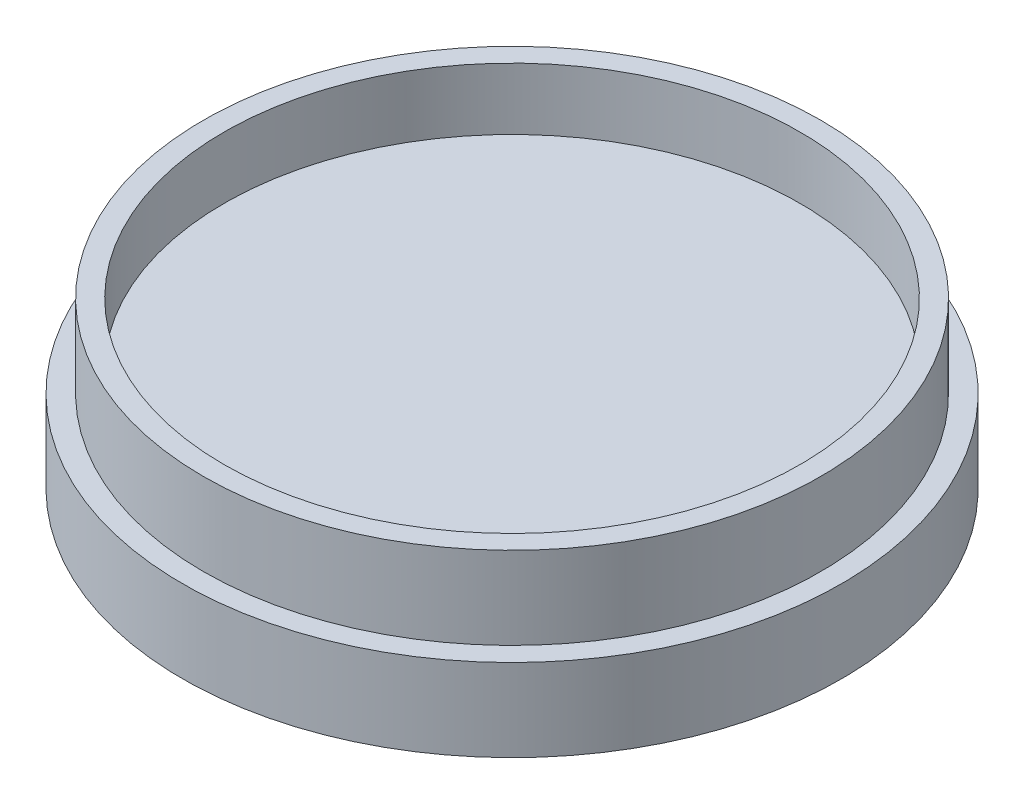
from build123d import *

# Parameters (mm, degrees)
SKETCH1_R           = 95.149999946
BOSS_EXTRUDE1_DEPTH = 25.4
SKETCH2_R           = 88.8
CUT_EXTRUDE1_DEPTH  = 19.05
SKETCH3_R           = 101.6
BOSS_EXTRUDE2_DEPTH = 25.4
SKETCH4_R           = 12.827
CUT_EXTRUDE2_DEPTH  = 19.05


with BuildPart() as part:
    # Sketch1 → Boss-Extrude1 (new body)
    with BuildSketch(Plane(origin=(0, 0, 0), x_dir=(1, 0, 0), z_dir=(0, 1, 0))):
        Circle(SKETCH1_R)
    extrude(amount=BOSS_EXTRUDE1_DEPTH)

    # Sketch2 → Cut-Extrude1 (cut)
    with BuildSketch(Plane(origin=(0, 25.4, 0), x_dir=(1, 0, 0), z_dir=(0, 1, 0))):
        Circle(SKETCH2_R)
    extrude(amount=-CUT_EXTRUDE1_DEPTH, mode=Mode.SUBTRACT)

    # Sketch3 → Boss-Extrude2 (add)
    with BuildSketch(Plane.XZ):
        Circle(SKETCH3_R)
    extrude(amount=BOSS_EXTRUDE2_DEPTH)

    # Sketch4 → Cut-Extrude2 (cut)
    with BuildSketch(Plane.XZ.offset(25.4)):
        with Locations((0, 82.55)):
            Circle(SKETCH4_R)
        with Locations((78.50971542, 25.509352886)):
            Circle(SKETCH4_R)
        with Locations((48.521672577, -66.784352886)):
            Circle(SKETCH4_R)
        with Locations((-48.521672577, -66.784352886)):
            Circle(SKETCH4_R)
        with Locations((-78.50971542, 25.509352886)):
            Circle(SKETCH4_R)
    extrude(amount=-CUT_EXTRUDE2_DEPTH, mode=Mode.SUBTRACT)


solid = part.part
